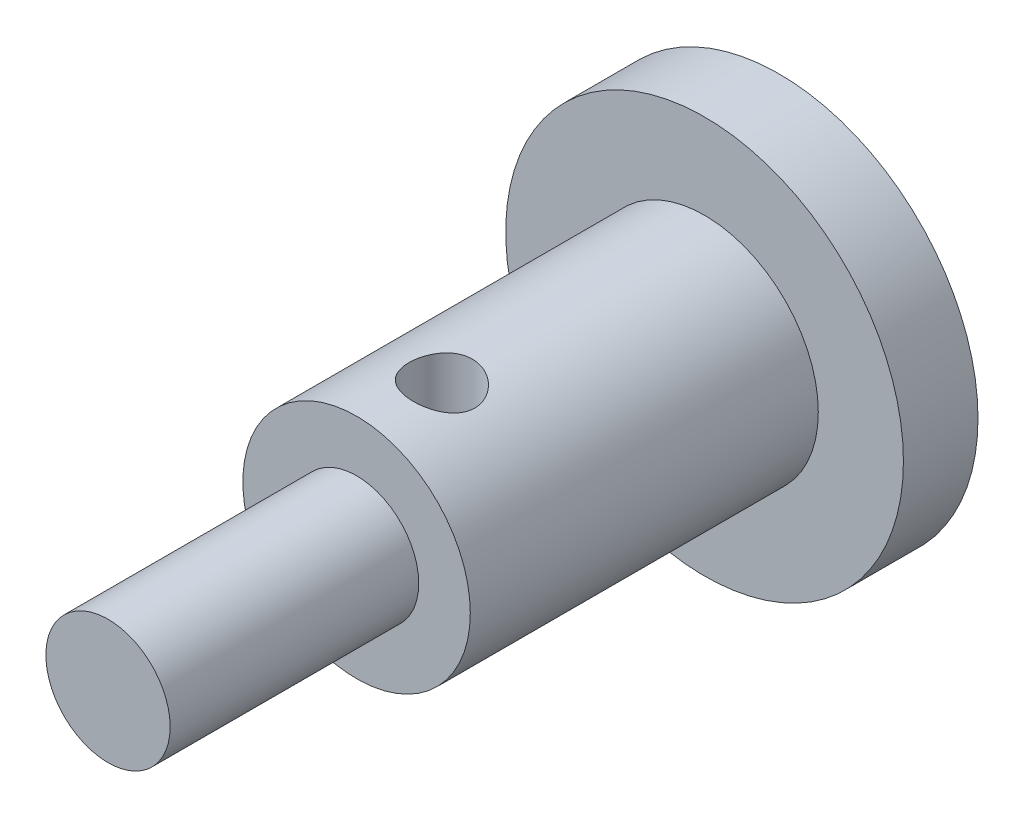
from build123d import *

# Parameters (mm, degrees)
SKETCH1_R           = 8
BOSS_EXTRUDE1_DEPTH = 3
SKETCH2_R           = 4.575
BOSS_EXTRUDE2_DEPTH = 14
SKETCH3_R           = 2.5
BOSS_EXTRUDE3_DEPTH = 10
SKETCH4_R           = 1.325
CUT_EXTRUDE1_DEPTH  = 7.5


with BuildPart() as part:
    # Sketch1 → Boss-Extrude1 (new body)
    with BuildSketch(Plane.XY):
        Circle(SKETCH1_R)
    extrude(amount=BOSS_EXTRUDE1_DEPTH)

    # Sketch2 → Boss-Extrude2 (add)
    with BuildSketch(Plane.XY.offset(3)):
        Circle(SKETCH2_R)
    extrude(amount=BOSS_EXTRUDE2_DEPTH)

    # Sketch3 → Boss-Extrude3 (add)
    with BuildSketch(Plane.XY.offset(17)):
        Circle(SKETCH3_R)
    extrude(amount=BOSS_EXTRUDE3_DEPTH)

    # Sketch4 → Cut-Extrude1 (cut, symmetric)
    with BuildSketch(Plane(origin=(0, 0, 0), x_dir=(1, 0, 0), z_dir=(0, 1, 0))):
        with Locations((0.425, -13.99354762)):
            Circle(SKETCH4_R)
    extrude(amount=CUT_EXTRUDE1_DEPTH, both=True, mode=Mode.SUBTRACT)


solid = part.part
